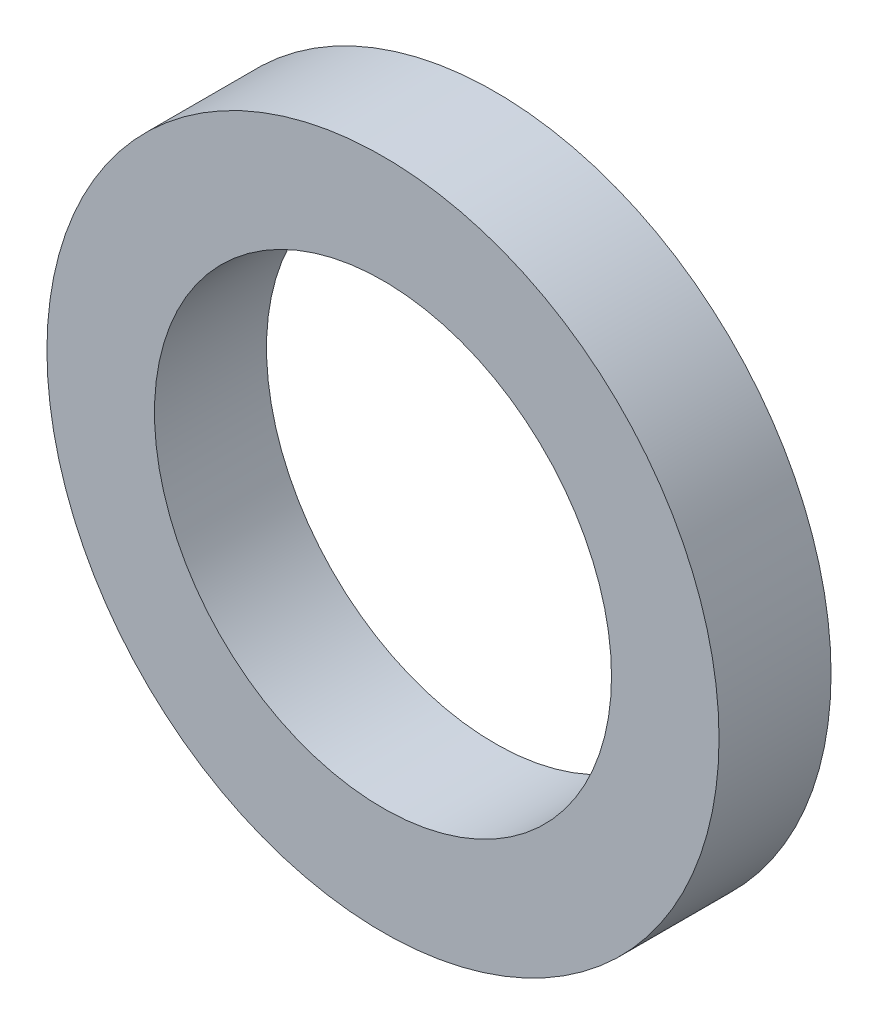
from build123d import *

# Parameters (mm, degrees)
SKETCH1_R           = 9.525
SKETCH1_R_2         = 6.477
BOSS_EXTRUDE1_DEPTH = 3.175


with BuildPart() as part:
    # Sketch1 → Boss-Extrude1 (new body)
    with BuildSketch(Plane.XY):
        Circle(SKETCH1_R)
        Circle(SKETCH1_R_2, mode=Mode.SUBTRACT)
    extrude(amount=BOSS_EXTRUDE1_DEPTH)


solid = part.part
